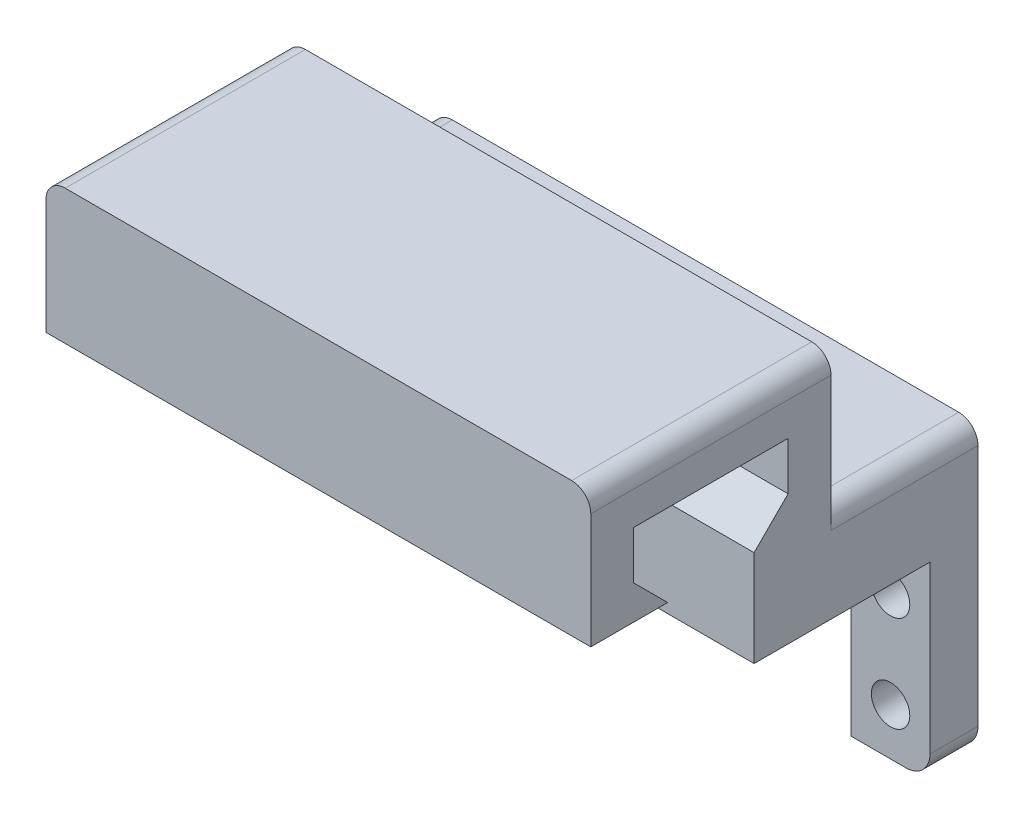
from build123d import *

# Parameters (mm, degrees)
SKETCH1_R               = 2
FORMA_B_SICA_DEPTH      = 5
FORMA_B_SICA_2_DEPTH    = 5
BOSS_EXTRUDE2_DEPTH     = 23.3
CARRIL_CREMALLERA_DEPTH = 56.7
ELIMINAR_FILETE_DEPTH   = 23.3
FILLET2_R               = 2


with BuildPart() as part:
    # Sketch1 → Forma básica (new body)
    with BuildSketch(Plane.XY):
        with BuildLine():
            ThreePointArc((-25.85, -9.9), (-27.617766953, -9.167766953), (-28.35, -7.4))
            Line((-28.35, -7.4), (-28.35, 9.9))
            Line((-28.35, 9.9), (-20.15, 9.9))
            Line((-20.15, 9.9), (-20.15, -9.9))
            Line((-20.15, -9.9), (-25.85, -9.9))
        make_face()
        with Locations((-24.25, -5)):
            Circle(SKETCH1_R, mode=Mode.SUBTRACT)
        with Locations((-24.25, 5)):
            Circle(SKETCH1_R, mode=Mode.SUBTRACT)
    extrude(amount=FORMA_B_SICA_DEPTH)



with BuildPart() as body_2:
    # Sketch1 → Forma b_sica 2 (new body)
    with BuildSketch(Plane.XY):
        with BuildLine():
            ThreePointArc((28.35, -7.4), (27.617766953, -9.167766953), (25.85, -9.9))
            Line((25.85, -9.9), (20.15, -9.9))
            Line((20.15, -9.9), (20.15, 9.9))
            Line((20.15, 9.9), (28.35, 9.9))
            Line((28.35, 9.9), (28.35, -7.4))
        make_face()
        with Locations((24.25, 5)):
            Circle(SKETCH1_R, mode=Mode.SUBTRACT)
        with Locations((24.25, -5)):
            Circle(SKETCH1_R, mode=Mode.SUBTRACT)
    extrude(amount=FORMA_B_SICA_2_DEPTH)


with BuildPart() as part_1:
    add(part.part)

    add(body_2.part)  # Boss-Extrude2 merges body 2
    # Sketch1_3 → Boss-Extrude2 (add)
    with BuildSketch(Plane.XY):
        with BuildLine():
            Line((-28.35, 9.9), (-20.15, 9.9))
            Line((-20.15, 9.9), (20.15, 9.9))
            Line((20.15, 9.9), (28.35, 9.9))
            Line((28.35, 9.9), (28.35, 17.4))
            ThreePointArc((28.35, 17.4), (27.617766953, 19.167766953), (25.85, 19.9))
            Line((25.85, 19.9), (-25.85, 19.9))
            ThreePointArc((-25.85, 19.9), (-27.617766953, 19.167766953), (-28.35, 17.4))
            Line((-28.35, 17.4), (-28.35, 9.9))
        make_face()
    extrude(amount=BOSS_EXTRUDE2_DEPTH)

    # Sketch2 → Carril cremallera (add)
    with BuildSketch(Plane(origin=(28.35, 0, 0), x_dir=(0, 0, -1), z_dir=(1, 0, 0))):
        Polygon((-23.3, 19.9), (-19.764466094, 23.435533906), (-19.764466094, 28.435533906), (-35.834466094, 28.435533906), (-35.834466094, 23.435533906), (-32.298932188, 19.9), (-40.298932188, 19.9), (-40.298932188, 33.9), (-15.3, 33.9), (-15.3, 19.9), align=None)
    extrude(amount=-CARRIL_CREMALLERA_DEPTH)

    # Sketch3 → Eliminar filete (add)
    with BuildSketch(Plane.XY.offset(23.3)):
        with BuildLine():
            Line((-28.35, 17.4), (-28.35, 19.9))
            Line((-28.35, 19.9), (-25.85, 19.9))
            ThreePointArc((-25.85, 19.9), (-27.617766953, 19.167766953), (-28.35, 17.4))
        make_face()
        with BuildLine():
            Line((28.35, 19.9), (25.85, 19.9))
            ThreePointArc((25.85, 19.9), (27.617766953, 19.167766953), (28.35, 17.4))
            Line((28.35, 17.4), (28.35, 19.9))
        make_face()
    extrude(amount=-ELIMINAR_FILETE_DEPTH)

    # Fillet2
    fillet2_edges = [part_1.edges().sort_by_distance(p)[0] for p in [
        (28.35, 33.9, 27.799466094),
        (-28.35, 33.9, 27.799466094),
        (-28.35, 19.9, 7.65),
        (28.35, 19.9, 7.65),
    ]]
    fillet(fillet2_edges, radius=FILLET2_R)


solid = part_1.part
